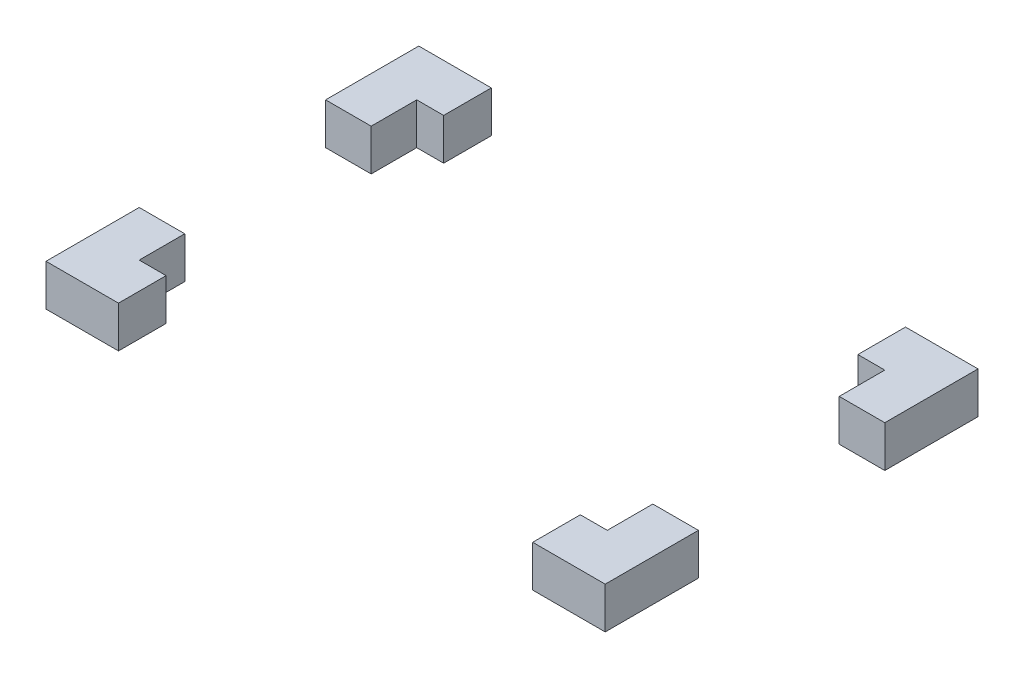
from build123d import *

# Parameters (mm, degrees)
SKETCH1_W           = 135
SKETCH1_H           = 90
SKETCH1_W_2         = 113
SKETCH1_H_2         = 67
BOSS_EXTRUDE1_DEPTH = 10
SKETCH2_W           = 45
SKETCH2_H           = 35
CUT_EXTRUDE1_DEPTH  = 300
SKETCH3_W           = 100
SKETCH3_H           = 120.605427014
CUT_EXTRUDE2_DEPTH  = 25


with BuildPart() as part:
    # Sketch1 → Boss-Extrude1 (new body)
    with BuildSketch(Plane(origin=(0, 0, 0), x_dir=(1, 0, 0), z_dir=(0, 1, 0))):
        Rectangle(SKETCH1_W, SKETCH1_H)
        Rectangle(SKETCH1_W_2, SKETCH1_H_2, mode=Mode.SUBTRACT)
    extrude(amount=BOSS_EXTRUDE1_DEPTH)

    # Sketch2 → Cut-Extrude1 (cut, symmetric)
    with BuildSketch(Plane.ZY.offset(-56.5)):
        with Locations((0, -2.5)):
            Rectangle(SKETCH2_W, SKETCH2_H)
    extrude(amount=CUT_EXTRUDE1_DEPTH, both=True, mode=Mode.SUBTRACT)

    # Sketch3 → Cut-Extrude2 (cut, symmetric)
    with BuildSketch(Plane(origin=(0, 10, 0), x_dir=(1, 0, 0), z_dir=(0, 1, 0))):
        with Locations((0, -1.453077434)):
            Rectangle(SKETCH3_W, SKETCH3_H)
    extrude(amount=CUT_EXTRUDE2_DEPTH, both=True, mode=Mode.SUBTRACT)


solid = part.part
